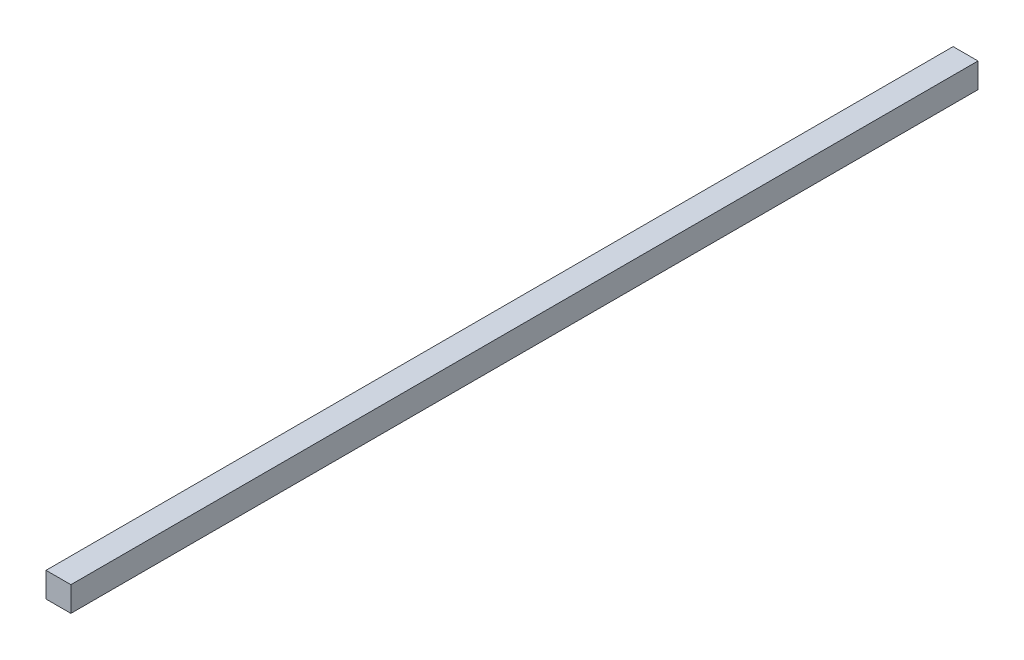
from build123d import *

# Parameters (mm, degrees)
SKETCH1_W           = 20
SKETCH1_H           = 20
BOSS_EXTRUDE1_DEPTH = 364.5


with BuildPart() as part:
    # Sketch1 → Boss-Extrude1 (new body, symmetric)
    with BuildSketch(Plane.XY):
        Rectangle(SKETCH1_W, SKETCH1_H)
    extrude(amount=BOSS_EXTRUDE1_DEPTH, both=True)


solid = part.part
